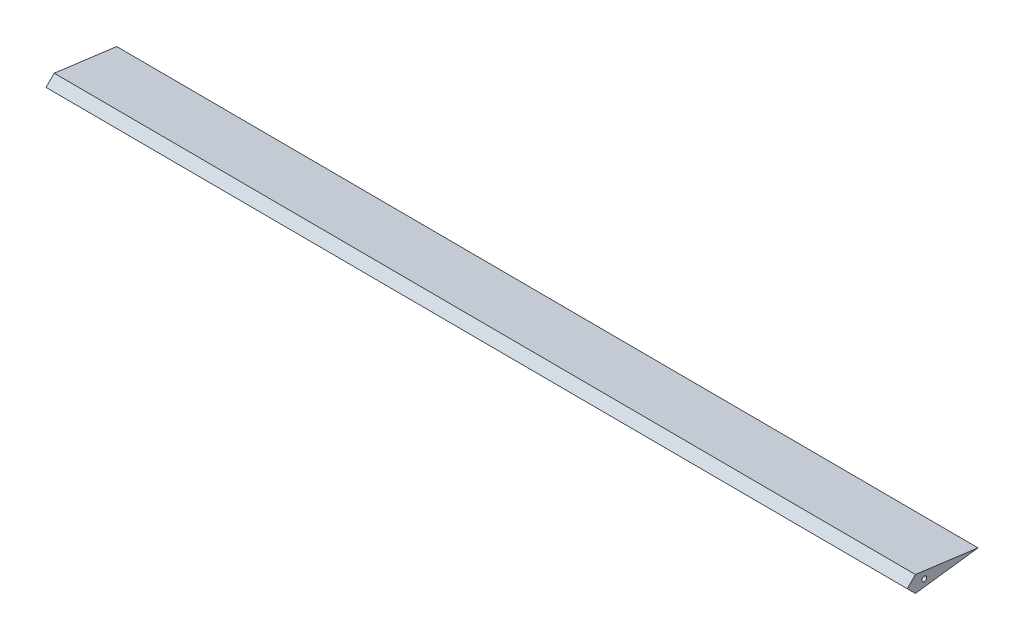
from build123d import *

# Parameters (mm, degrees)
AILERON_DEPTH           = 482.696053238
SKETCH2_R               = 2.75
CUT_EXTRUDE2_DEPTH      = 483.696053238
CUT_EXTRUDE2_DEPTH_BACK = 484.024800506


with BuildPart() as part:
    # aileron_root → aileron (new body, symmetric, along a direction that is not the sketch's normal)
    with BuildSketch(Plane(origin=(0, 0, 0), x_dir=(0, 0, -1), z_dir=(1, 0, 0))):
        Polygon((-80, -10.492874398), (-80, 10.492874398), (0, 0), align=None)
    extrude(amount=AILERON_DEPTH, dir=(0.999991557, 0, 0.004109341), both=True)

    # Sketch2 → Cut-Extrude2 (cut, two sides)
    with BuildSketch(Plane(origin=(0, 0, 0), x_dir=(-0.004109341, 0, 0.999991557), z_dir=(-0.999991557, 0, -0.004109341))) as cut_extrude2_sk:
        with Locations((60, 0)):
            Circle(SKETCH2_R)
        Polygon((78.99932453, 0), (68.506450132, -10.492874398), (79.99932453, -10.492874398), (79.99932453, 10.492874398), (68.506450132, 10.492874398), align=None)
    extrude(amount=CUT_EXTRUDE2_DEPTH, mode=Mode.SUBTRACT)
    extrude(cut_extrude2_sk.sketch, amount=-CUT_EXTRUDE2_DEPTH_BACK, mode=Mode.SUBTRACT)


solid = part.part
